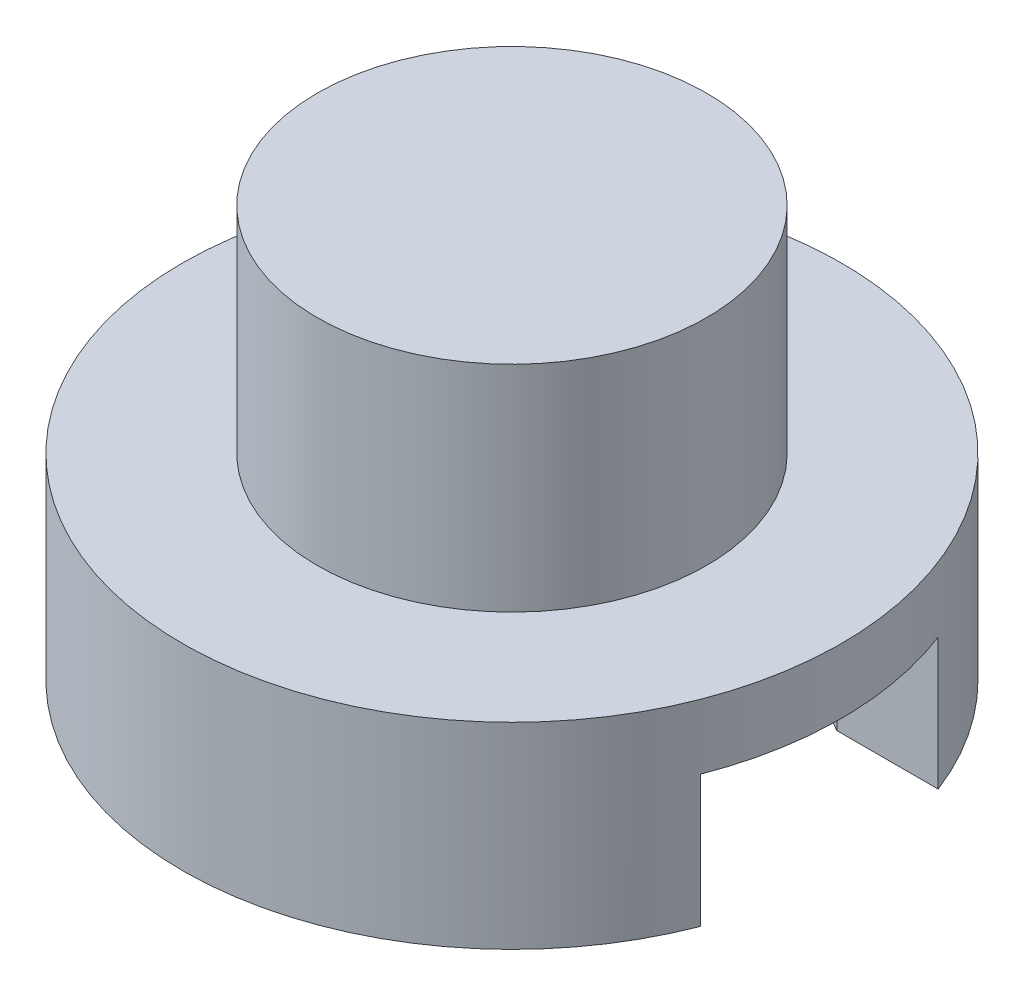
from build123d import *

# Parameters (mm, degrees)
BOSS_EXTRUDE1_DEPTH = 25.4
BOSS_EXTRUDE3_DEPTH = 5.08
SKETCH4_W           = 37.4
SKETCH4_H           = 25.4
CUT_EXTRUDE1_DEPTH  = 25.4
SKETCH5_R           = 12.7
BOSS_EXTRUDE4_DEPTH = 2.5
SKETCH6_R           = 7.5
BOSS_EXTRUDE5_DEPTH = 8.272


with BuildPart() as part:
    # Sketch1 → Boss-Extrude1 (new body)
    with BuildSketch(Plane.XY):
        Polygon((-10.189534884, 0), (-10.189534884, 9), (15.210465116, 9), (15.210465116, 0), (21.210465116, 0), (21.210465116, 20.17346), (-16.189534884, 20.17346), (-16.189534884, 0), align=None)
    extrude(amount=BOSS_EXTRUDE1_DEPTH)

    # Sketch3 → Boss-Extrude3 (add)
    with BuildSketch(Plane(origin=(0, 20.17346, 0), x_dir=(1, 0, 0), z_dir=(0, 1, 0))):
        with BuildLine():
            Line((14.354818113, -17.282717762), (10.447965116, -17.282717762))
            Line((10.447965116, -17.282717762), (2.510465116, -21.865435523))
            Line((2.510465116, -21.865435523), (-5.427034884, -17.282717762))
            Line((-5.427034884, -17.282717762), (-5.427034884, -8.117282238))
            Line((-5.427034884, -8.117282238), (2.510465116, -3.534564477))
            Line((2.510465116, -3.534564477), (10.447965116, -8.117282238))
            Line((10.447965116, -8.117282238), (14.354818113, -8.117282238))
            ThreePointArc((14.354818113, -8.117282238), (-10.189534884, -12.7), (14.354818113, -17.282717762))
        make_face()
    extrude(amount=BOSS_EXTRUDE3_DEPTH)

    # Sketch4 → Cut-Extrude1 (cut)
    with BuildSketch(Plane(origin=(0, 20.17346, 0), x_dir=(1, 0, 0), z_dir=(0, 1, 0))):
        with Locations((2.510465116, -12.7)):
            Rectangle(SKETCH4_W, SKETCH4_H)
    extrude(amount=-CUT_EXTRUDE1_DEPTH, mode=Mode.SUBTRACT)

    # Sketch5 → Boss-Extrude4 (add)
    with BuildSketch(Plane(origin=(0, 25.25346, 0), x_dir=(1, 0, 0), z_dir=(0, 1, 0))):
        with Locations((2.510465116, -12.7)):
            Circle(SKETCH5_R)
    extrude(amount=BOSS_EXTRUDE4_DEPTH)

    # Sketch6 → Boss-Extrude5 (add)
    with BuildSketch(Plane(origin=(0, 27.75346, 0), x_dir=(1, 0, 0), z_dir=(0, 1, 0))):
        with Locations((2.510465116, -12.7)):
            Circle(SKETCH6_R)
    extrude(amount=BOSS_EXTRUDE5_DEPTH)


solid = part.part
